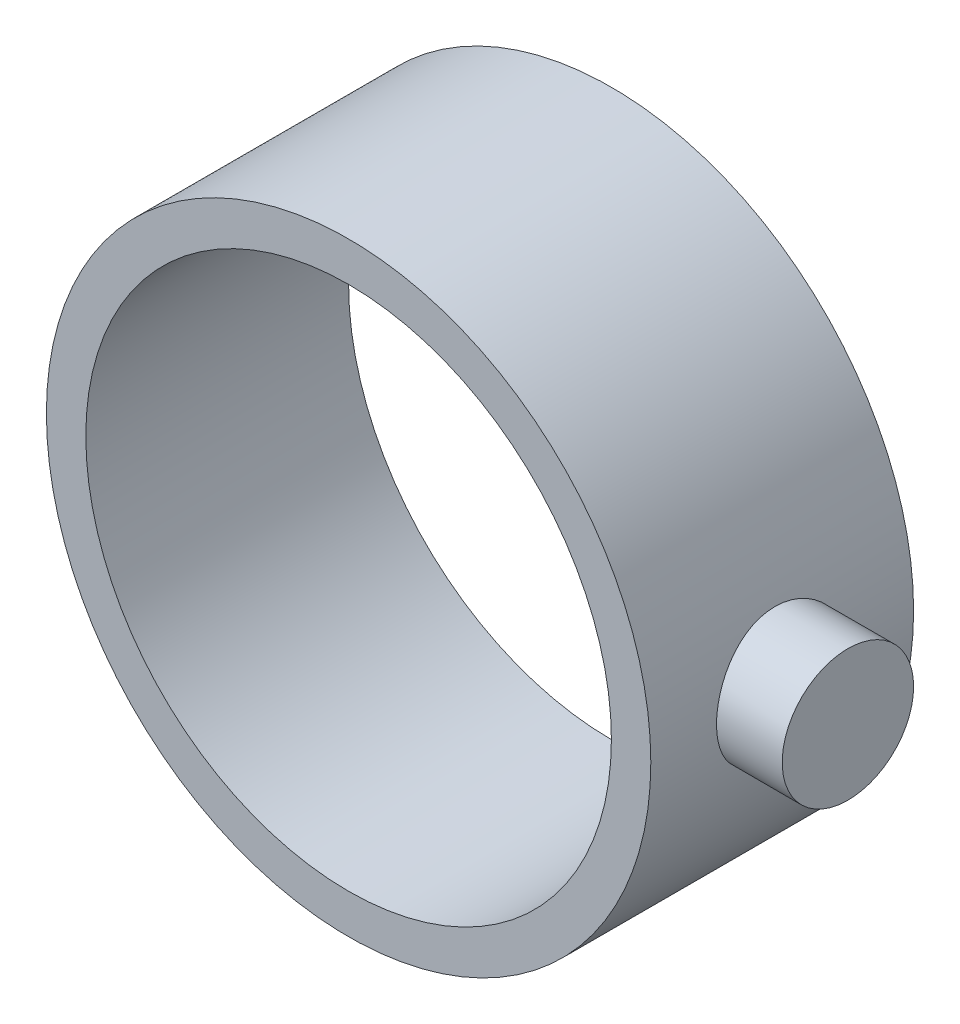
from build123d import *

# Parameters (mm, degrees)
ESQUISSE1_R                    = 23
ESQUISSE1_R_2                  = 20
BOSS_EXTRU_1_DEPTH             = 10
BOSS_EXTRU_2_REACH             = 54.393
BOSS_EXTRU_2_END_RADIUS        = 23
ESQUISSE2_R                    = 5
BOSS_EXTRU_2_DIRECTION_2_DEPTH = 5


with BuildPart() as part:
    # Esquisse1 → Boss.-Extru.1 (new, symmetric)
    with BuildSketch(Plane.XY):
        Circle(ESQUISSE1_R)
        Circle(ESQUISSE1_R_2, mode=Mode.SUBTRACT)
    extrude(amount=BOSS_EXTRU_1_DEPTH, both=True)

    # Boss.-Extru.2: up to this cylinder (the profile starts outside it)
    boss_extru_2_end = Plane(origin=(0, 0, 0), z_dir=(0, 0, -1)) * Cylinder(BOSS_EXTRU_2_END_RADIUS, 155.786, mode=Mode.PRIVATE)
    # Esquisse2 → Boss.-Extru.2 (add, up to the surface)
    with BuildSketch(Plane(origin=(23, 0, 0), x_dir=(0, 0, -1), z_dir=(1, 0, 0)), mode=Mode.PRIVATE) as boss_extru_2_sk1:
        Circle(ESQUISSE2_R)
    boss_extru_2_tool1 = extrude(boss_extru_2_sk1.sketch, amount=-BOSS_EXTRU_2_REACH, mode=Mode.PRIVATE) - boss_extru_2_end
    add(boss_extru_2_tool1.solids().sort_by_distance((23, 0, 0))[0])
    add(boss_extru_2_tool1.solids().sort_by_distance((23, 0, 0))[1])

    # Esquisse2 → Boss.-Extru.2 direction 2 (add)
    with BuildSketch(Plane(origin=(23, 0, 0), x_dir=(0, 0, -1), z_dir=(1, 0, 0))):
        Circle(ESQUISSE2_R)
    extrude(amount=BOSS_EXTRU_2_DIRECTION_2_DEPTH)


solid = part.part
